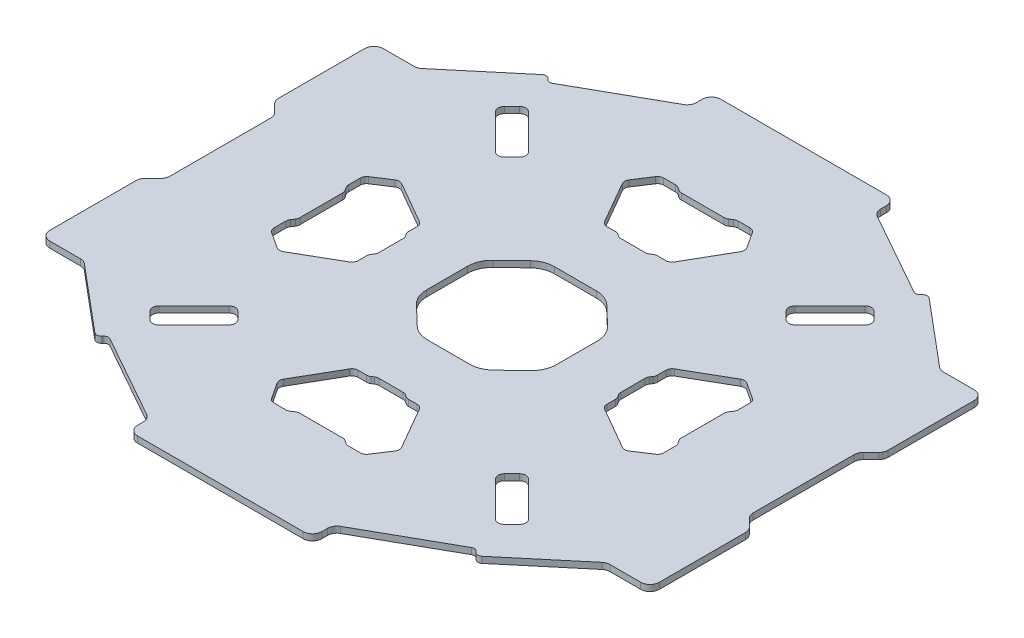
from build123d import *

# Parameters (mm, degrees)
ESTRUSIONE_ESTRUSIONE1_DEPTH = 2


with BuildPart() as part:
    # Schizzo3 → Estrusione-Estrusione1 (new body)
    with BuildSketch(Plane(origin=(0, 0, 0), x_dir=(1, 0, 0), z_dir=(0, 1, 0))):
        with BuildLine():
            Line((-226.062548699, 21.450885989), (-226.062548699, 53.965604615))
            ThreePointArc((-226.062548699, 53.965604615), (-226.290910101, 55.113654912), (-226.941228355, 56.086924959))
            Line((-226.941228355, 56.086924959), (-229.426509729, 58.572206333))
            ThreePointArc((-229.426509729, 58.572206333), (-230.076827983, 59.545476379), (-230.305189386, 60.693526677))
            Line((-230.305189386, 60.693526677), (-230.305189386, 88.450885989))
            ThreePointArc((-230.305189386, 88.450885989), (-229.426509729, 90.572206333), (-227.305189386, 91.450885989))
            Line((-227.305189386, 91.450885989), (-217.397100089, 91.450885989))
            ThreePointArc((-217.397100089, 91.450885989), (-216.371039659, 91.631808127), (-215.468737259, 92.15275266))
            Line((-215.468737259, 92.15275266), (-194.472922757, 109.770332866))
            ThreePointArc((-194.472922757, 109.770332866), (-193.378007728, 110.115558248), (-192.359674678, 109.585447615))
            Line((-192.359674678, 109.585447615), (-192.195095041, 109.389309242))
            ThreePointArc((-192.195095041, 109.389309242), (-191.315026723, 108.877807801), (-190.311081204, 109.045877314))
            Line((-190.311081204, 109.045877314), (-163.286363151, 124.235184019))
            ThreePointArc((-163.286363151, 124.235184019), (-162.166886622, 125.335432657), (-161.756257495, 126.850410704))
            Line((-161.756257495, 126.850410704), (-161.756257495, 128.708245302))
            ThreePointArc((-161.756257495, 128.708245302), (-160.877577839, 130.829565646), (-158.756257495, 131.708245302))
            Line((-158.756257495, 131.708245302), (-105.368839902, 131.708245302))
            ThreePointArc((-105.368839902, 131.708245302), (-103.247519558, 130.829565646), (-102.368839902, 128.708245302))
            Line((-102.368839902, 128.708245302), (-102.368839902, 126.850410704))
            ThreePointArc((-102.368839902, 126.850410704), (-101.958210775, 125.335432657), (-100.838734247, 124.235184019))
            Line((-100.838734247, 124.235184019), (-73.814016193, 109.045877314))
            ThreePointArc((-73.814016193, 109.045877314), (-72.810070674, 108.877807801), (-71.930002356, 109.389309242))
            Line((-71.930002356, 109.389309242), (-71.76542272, 109.585447615))
            ThreePointArc((-71.76542272, 109.585447615), (-70.747089669, 110.115558248), (-69.65217464, 109.770332865))
            Line((-69.65217464, 109.770332865), (-48.656360138, 92.15275266))
            ThreePointArc((-48.656360138, 92.15275266), (-47.754057739, 91.631808127), (-46.727997309, 91.450885989))
            Line((-46.727997309, 91.450885989), (-36.819908011, 91.450885989))
            ThreePointArc((-36.819908011, 91.450885989), (-34.698587668, 90.572206333), (-33.819908011, 88.450885989))
            Line((-33.819908011, 88.450885989), (-33.819908011, 60.693526677))
            ThreePointArc((-33.819908011, 60.693526677), (-34.048269414, 59.545476379), (-34.698587668, 58.572206333))
            Line((-34.698587668, 58.572206333), (-37.183869042, 56.086924959))
            ThreePointArc((-37.183869042, 56.086924959), (-37.834187296, 55.113654912), (-38.062548699, 53.965604615))
            Line((-38.062548699, 53.965604615), (-38.062548699, 21.450885989))
            ThreePointArc((-38.062548699, 21.450885989), (-37.834187296, 20.302835692), (-37.183869042, 19.329565646))
            Line((-37.183869042, 19.329565646), (-34.698587668, 16.844284272))
            ThreePointArc((-34.698587668, 16.844284272), (-34.048269414, 15.871014225), (-33.819908011, 14.722963928))
            Line((-33.819908011, 14.722963928), (-33.819908011, -13.034395385))
            ThreePointArc((-33.819908011, -13.034395385), (-34.698587668, -15.155715728), (-36.819908011, -16.034395385))
            Line((-36.819908011, -16.034395385), (-46.727997309, -16.034395385))
            ThreePointArc((-46.727997309, -16.034395385), (-47.754057739, -16.215317522), (-48.656360138, -16.736262055))
            Line((-48.656360138, -16.736262055), (-69.65217464, -34.353842261))
            ThreePointArc((-69.65217464, -34.353842261), (-70.747089669, -34.699067643), (-71.76542272, -34.168957011))
            Line((-71.76542272, -34.168957011), (-71.930002356, -33.972818637))
            ThreePointArc((-71.930002356, -33.972818637), (-72.810070674, -33.461317196), (-73.814016193, -33.629386709))
            Line((-73.814016193, -33.629386709), (-100.838734247, -48.818693414))
            ThreePointArc((-100.838734247, -48.818693414), (-101.958210775, -49.918942052), (-102.368839902, -51.433920099))
            Line((-102.368839902, -51.433920099), (-102.368839902, -53.291754698))
            ThreePointArc((-102.368839902, -53.291754698), (-103.247519558, -55.413075041), (-105.368839902, -56.291754698))
            Line((-105.368839902, -56.291754698), (-158.756257495, -56.291754698))
            ThreePointArc((-158.756257495, -56.291754698), (-160.877577839, -55.413075041), (-161.756257495, -53.291754698))
            Line((-161.756257495, -53.291754698), (-161.756257495, -51.433920099))
            ThreePointArc((-161.756257495, -51.433920099), (-162.166886622, -49.918942052), (-163.286363151, -48.818693414))
            Line((-163.286363151, -48.818693414), (-190.311081204, -33.629386709))
            ThreePointArc((-190.311081204, -33.629386709), (-191.315026723, -33.461317196), (-192.195095041, -33.972818637))
            Line((-192.195095041, -33.972818637), (-192.359674678, -34.168957011))
            ThreePointArc((-192.359674678, -34.168957011), (-193.378007728, -34.699067643), (-194.472922757, -34.353842261))
            Line((-194.472922757, -34.353842261), (-215.468737259, -16.736262055))
            ThreePointArc((-215.468737259, -16.736262055), (-216.371039659, -16.215317522), (-217.397100089, -16.034395385))
            Line((-217.397100089, -16.034395385), (-227.305189386, -16.034395385))
            ThreePointArc((-227.305189386, -16.034395385), (-229.426509729, -15.155715728), (-230.305189386, -13.034395385))
            Line((-230.305189386, -13.034395385), (-230.305189386, 14.722963928))
            ThreePointArc((-230.305189386, 14.722963928), (-230.076827983, 15.871014225), (-229.426509729, 16.844284272))
            Line((-229.426509729, 16.844284272), (-226.941228355, 19.329565646))
            ThreePointArc((-226.941228355, 19.329565646), (-226.290910101, 20.302835692), (-226.062548699, 21.450885989))
        make_face()
        with BuildLine():
            Line((-193.562548699, 30.804307286), (-193.562548699, 44.612183318))
            ThreePointArc((-193.562548699, 44.612183318), (-193.645860549, 45.183415789), (-193.888855234, 45.707057826))
            Line((-193.888855234, 45.707057826), (-194.544575535, 46.709432779))
            ThreePointArc((-194.544575535, 46.709432779), (-194.787570221, 47.233074816), (-194.870882071, 47.804307286))
            Line((-194.870882071, 47.804307286), (-194.870882071, 51.626654782))
            ThreePointArc((-194.870882071, 51.626654782), (-194.630107613, 52.578035617), (-193.965756578, 53.300348246))
            Line((-193.965756578, 53.300348246), (-188.785660294, 56.688994666))
            ThreePointArc((-188.785660294, 56.688994666), (-187.747791156, 57.014488633), (-186.693060988, 56.748663606))
            Line((-186.693060988, 56.748663606), (-173.159698407, 48.958849181))
            ThreePointArc((-173.159698407, 48.958849181), (-172.426029317, 48.226623731), (-172.157423206, 47.225486777))
            Line((-172.157423206, 47.225486777), (-172.157423206, 44.478000751))
            ThreePointArc((-172.157423206, 44.478000751), (-172.074111356, 43.90676828), (-171.83111667, 43.383126243))
            Line((-171.83111667, 43.383126243), (-171.388855234, 42.707057826))
            ThreePointArc((-171.388855234, 42.707057826), (-171.145860549, 42.183415789), (-171.062548699, 41.612183318))
            Line((-171.062548699, 41.612183318), (-171.062548699, 33.804307286))
            ThreePointArc((-171.062548699, 33.804307286), (-171.145860549, 33.233074816), (-171.388855234, 32.709432779))
            Line((-171.388855234, 32.709432779), (-171.83111667, 32.033364361))
            ThreePointArc((-171.83111667, 32.033364361), (-172.074111356, 31.509722324), (-172.157423206, 30.938489854))
            Line((-172.157423206, 30.938489854), (-172.157423206, 28.191003828))
            ThreePointArc((-172.157423206, 28.191003828), (-172.426029317, 27.189866874), (-173.159698407, 26.457641423))
            Line((-173.159698407, 26.457641423), (-186.693060988, 18.667826999))
            ThreePointArc((-186.693060988, 18.667826999), (-187.747791156, 18.402001971), (-188.785660294, 18.727495938))
            Line((-188.785660294, 18.727495938), (-193.965756578, 22.116142358))
            ThreePointArc((-193.965756578, 22.116142358), (-194.630107613, 22.838454988), (-194.870882071, 23.789835823))
            Line((-194.870882071, 23.789835823), (-194.870882071, 27.612183318))
            ThreePointArc((-194.870882071, 27.612183318), (-194.787570221, 28.183415789), (-194.544575535, 28.707057826))
            Line((-194.544575535, 28.707057826), (-193.888855234, 29.709432779))
            ThreePointArc((-193.888855234, 29.709432779), (-193.645860549, 30.233074816), (-193.562548699, 30.804307286))
        make_face(mode=Mode.SUBTRACT)
        with BuildLine():
            Line((-180.324443139, 80.666838895), (-191.638151638, 91.980547394))
            ThreePointArc((-191.638151638, 91.980547394), (-192.223938076, 93.394760956), (-191.638151638, 94.808974518))
            Line((-191.638151638, 94.808974518), (-189.163277904, 97.283848253))
            ThreePointArc((-189.163277904, 97.283848253), (-187.749064341, 97.86963469), (-186.334850779, 97.283848253))
            Line((-186.334850779, 97.283848253), (-175.02114228, 85.970139754))
            ThreePointArc((-175.02114228, 85.970139754), (-174.435355842, 84.555926191), (-175.02114228, 83.141712629))
            Line((-175.02114228, 83.141712629), (-177.496016014, 80.666838895))
            ThreePointArc((-177.496016014, 80.666838895), (-178.910229577, 80.081052457), (-180.324443139, 80.666838895))
        make_face(mode=Mode.SUBTRACT)
        with BuildLine():
            Line((-125.158610672, 99.208245313), (-138.966486704, 99.208245313))
            ThreePointArc((-138.966486704, 99.208245313), (-139.537719175, 99.291557163), (-140.061361211, 99.534551849))
            Line((-140.061361211, 99.534551849), (-141.063736164, 100.19027215))
            ThreePointArc((-141.063736164, 100.19027215), (-141.587378201, 100.433266835), (-142.158610672, 100.516578685))
            Line((-142.158610672, 100.516578685), (-145.980958167, 100.516578685))
            ThreePointArc((-145.980958167, 100.516578685), (-146.932339002, 100.275804227), (-147.654651632, 99.611453193))
            Line((-147.654651632, 99.611453193), (-151.043298052, 94.431356909))
            ThreePointArc((-151.043298052, 94.431356909), (-151.368792019, 93.39348777), (-151.102966992, 92.338757603))
            Line((-151.102966992, 92.338757603), (-143.313152567, 78.805395021))
            ThreePointArc((-143.313152567, 78.805395021), (-142.580927117, 78.071725931), (-141.579790163, 77.80311982))
            Line((-141.579790163, 77.80311982), (-138.832304136, 77.80311982))
            ThreePointArc((-138.832304136, 77.80311982), (-138.261071666, 77.71980797), (-137.737429629, 77.476813285))
            Line((-137.737429629, 77.476813285), (-137.061361211, 77.034551849))
            ThreePointArc((-137.061361211, 77.034551849), (-136.537719175, 76.791557163), (-135.966486704, 76.708245313))
            Line((-135.966486704, 76.708245313), (-128.158610672, 76.708245313))
            ThreePointArc((-128.158610672, 76.708245313), (-127.587378201, 76.791557163), (-127.063736164, 77.034551849))
            Line((-127.063736164, 77.034551849), (-126.387667747, 77.476813285))
            ThreePointArc((-126.387667747, 77.476813285), (-125.86402571, 77.71980797), (-125.292793239, 77.80311982))
            Line((-125.292793239, 77.80311982), (-122.545307213, 77.80311982))
            ThreePointArc((-122.545307213, 77.80311982), (-121.544170259, 78.071725931), (-120.811944809, 78.805395021))
            Line((-120.811944809, 78.805395021), (-113.022130384, 92.338757603))
            ThreePointArc((-113.022130384, 92.338757603), (-112.756305357, 93.39348777), (-113.081799324, 94.431356909))
            Line((-113.081799324, 94.431356909), (-116.470445744, 99.611453193))
            ThreePointArc((-116.470445744, 99.611453193), (-117.192758374, 100.275804227), (-118.144139208, 100.516578685))
            Line((-118.144139208, 100.516578685), (-121.966486704, 100.516578685))
            ThreePointArc((-121.966486704, 100.516578685), (-122.537719175, 100.433266835), (-123.061361211, 100.19027215))
            Line((-123.061361211, 100.19027215), (-124.063736164, 99.534551849))
            ThreePointArc((-124.063736164, 99.534551849), (-124.587378201, 99.291557163), (-125.158610672, 99.208245313))
        make_face(mode=Mode.SUBTRACT)
        with BuildLine():
            Line((-72.486945754, 94.808974513), (-74.961819488, 97.283848247))
            ThreePointArc((-74.961819488, 97.283848247), (-76.37603305, 97.869634685), (-77.790246613, 97.283848247))
            Line((-77.790246613, 97.283848247), (-89.103955112, 85.970139748))
            ThreePointArc((-89.103955112, 85.970139748), (-89.689741549, 84.555926186), (-89.103955112, 83.141712623))
            Line((-89.103955112, 83.141712623), (-86.629081378, 80.666838889))
            ThreePointArc((-86.629081378, 80.666838889), (-85.214867815, 80.081052452), (-83.800654253, 80.666838889))
            Line((-83.800654253, 80.666838889), (-72.486945754, 91.980547388))
            ThreePointArc((-72.486945754, 91.980547388), (-71.901159316, 93.394760951), (-72.486945754, 94.808974513))
        make_face(mode=Mode.SUBTRACT)
        with BuildLine():
            Line((-93.062548699, 41.612183318), (-93.062548699, 33.804307286))
            ThreePointArc((-93.062548699, 33.804307286), (-92.979236849, 33.233074816), (-92.736242163, 32.709432779))
            Line((-92.736242163, 32.709432779), (-92.293980727, 32.033364361))
            ThreePointArc((-92.293980727, 32.033364361), (-92.050986041, 31.509722324), (-91.967674191, 30.938489854))
            Line((-91.967674191, 30.938489854), (-91.967674191, 28.191003828))
            ThreePointArc((-91.967674191, 28.191003828), (-91.69906808, 27.189866874), (-90.96539899, 26.457641423))
            Line((-90.96539899, 26.457641423), (-77.432036409, 18.667826999))
            ThreePointArc((-77.432036409, 18.667826999), (-76.377306242, 18.402001971), (-75.339437103, 18.727495938))
            Line((-75.339437103, 18.727495938), (-70.159340819, 22.116142358))
            ThreePointArc((-70.159340819, 22.116142358), (-69.494989784, 22.838454988), (-69.254215326, 23.789835823))
            Line((-69.254215326, 23.789835823), (-69.254215326, 27.612183318))
            ThreePointArc((-69.254215326, 27.612183318), (-69.337527176, 28.183415789), (-69.580521862, 28.707057826))
            Line((-69.580521862, 28.707057826), (-70.236242163, 29.709432779))
            ThreePointArc((-70.236242163, 29.709432779), (-70.479236849, 30.233074816), (-70.562548699, 30.804307286))
            Line((-70.562548699, 30.804307286), (-70.562548699, 44.612183318))
            ThreePointArc((-70.562548699, 44.612183318), (-70.479236849, 45.183415789), (-70.236242163, 45.707057826))
            Line((-70.236242163, 45.707057826), (-69.580521862, 46.709432779))
            ThreePointArc((-69.580521862, 46.709432779), (-69.337527176, 47.233074816), (-69.254215326, 47.804307286))
            Line((-69.254215326, 47.804307286), (-69.254215326, 51.626654782))
            ThreePointArc((-69.254215326, 51.626654782), (-69.494989784, 52.578035617), (-70.159340819, 53.300348246))
            Line((-70.159340819, 53.300348246), (-75.339437103, 56.688994666))
            ThreePointArc((-75.339437103, 56.688994666), (-76.377306242, 57.014488633), (-77.432036409, 56.748663606))
            Line((-77.432036409, 56.748663606), (-90.96539899, 48.958849181))
            ThreePointArc((-90.96539899, 48.958849181), (-91.69906808, 48.226623731), (-91.967674191, 47.225486777))
            Line((-91.967674191, 47.225486777), (-91.967674191, 44.478000751))
            ThreePointArc((-91.967674191, 44.478000751), (-92.050986041, 43.90676828), (-92.293980727, 43.383126243))
            Line((-92.293980727, 43.383126243), (-92.736242163, 42.707057826))
            ThreePointArc((-92.736242163, 42.707057826), (-92.979236849, 42.183415789), (-93.062548699, 41.612183318))
        make_face(mode=Mode.SUBTRACT)
        with BuildLine():
            Line((-83.800654253, -5.250348285), (-72.486945754, -16.564056784))
            ThreePointArc((-72.486945754, -16.564056784), (-71.901159316, -17.978270346), (-72.486945754, -19.392483908))
            Line((-72.486945754, -19.392483908), (-74.961819488, -21.867357642))
            ThreePointArc((-74.961819488, -21.867357642), (-76.37603305, -22.45314408), (-77.790246613, -21.867357642))
            Line((-77.790246613, -21.867357642), (-89.103955112, -10.553649143))
            ThreePointArc((-89.103955112, -10.553649143), (-89.689741549, -9.139435581), (-89.103955112, -7.725222019))
            Line((-89.103955112, -7.725222019), (-86.629081378, -5.250348285))
            ThreePointArc((-86.629081378, -5.250348285), (-85.214867815, -4.664561847), (-83.800654253, -5.250348285))
        make_face(mode=Mode.SUBTRACT)
        with BuildLine():
            Line((-124.063736175, -24.118061233), (-123.061361222, -24.773781534))
            ThreePointArc((-123.061361222, -24.773781534), (-122.537719185, -25.01677622), (-121.966486715, -25.10008807))
            Line((-121.966486715, -25.10008807), (-118.144139219, -25.10008807))
            ThreePointArc((-118.144139219, -25.10008807), (-117.192758384, -24.859313612), (-116.470445755, -24.194962577))
            Line((-116.470445755, -24.194962577), (-113.081799335, -19.014866293))
            ThreePointArc((-113.081799335, -19.014866293), (-112.756305367, -17.976997155), (-113.022130395, -16.922266987))
            Line((-113.022130395, -16.922266987), (-120.811944819, -3.388904406))
            ThreePointArc((-120.811944819, -3.388904406), (-121.54417027, -2.655235316), (-122.545307224, -2.386629205))
            Line((-122.545307224, -2.386629205), (-125.29279325, -2.386629205))
            ThreePointArc((-125.29279325, -2.386629205), (-125.864025721, -2.303317355), (-126.387667757, -2.06032267))
            Line((-126.387667757, -2.06032267), (-127.063736175, -1.618061233))
            ThreePointArc((-127.063736175, -1.618061233), (-127.587378212, -1.375066548), (-128.158610682, -1.291754698))
            Line((-128.158610682, -1.291754698), (-135.966486715, -1.291754698))
            ThreePointArc((-135.966486715, -1.291754698), (-136.537719185, -1.375066548), (-137.061361222, -1.618061233))
            Line((-137.061361222, -1.618061233), (-137.73742964, -2.06032267))
            ThreePointArc((-137.73742964, -2.06032267), (-138.261071676, -2.303317355), (-138.832304147, -2.386629205))
            Line((-138.832304147, -2.386629205), (-141.579790173, -2.386629205))
            ThreePointArc((-141.579790173, -2.386629205), (-142.580927127, -2.655235316), (-143.313152578, -3.388904406))
            Line((-143.313152578, -3.388904406), (-151.102967002, -16.922266987))
            ThreePointArc((-151.102967002, -16.922266987), (-151.36879203, -17.976997155), (-151.043298062, -19.014866293))
            Line((-151.043298062, -19.014866293), (-147.654651643, -24.194962577))
            ThreePointArc((-147.654651643, -24.194962577), (-146.932339013, -24.859313612), (-145.980958178, -25.10008807))
            Line((-145.980958178, -25.10008807), (-142.158610682, -25.10008807))
            ThreePointArc((-142.158610682, -25.10008807), (-141.587378212, -25.01677622), (-141.063736175, -24.773781534))
            Line((-141.063736175, -24.773781534), (-140.061361222, -24.118061233))
            ThreePointArc((-140.061361222, -24.118061233), (-139.537719185, -23.875066548), (-138.966486715, -23.791754698))
            Line((-138.966486715, -23.791754698), (-125.158610682, -23.791754698))
            ThreePointArc((-125.158610682, -23.791754698), (-124.587378212, -23.875066548), (-124.063736175, -24.118061233))
        make_face(mode=Mode.SUBTRACT)
        with BuildLine():
            Line((-191.638151643, -19.392483908), (-189.163277909, -21.867357642))
            ThreePointArc((-189.163277909, -21.867357642), (-187.749064347, -22.45314408), (-186.334850784, -21.867357642))
            Line((-186.334850784, -21.867357642), (-175.021142286, -10.553649143))
            ThreePointArc((-175.021142286, -10.553649143), (-174.435355848, -9.139435581), (-175.021142286, -7.725222019))
            Line((-175.021142286, -7.725222019), (-177.49601602, -5.250348285))
            ThreePointArc((-177.49601602, -5.250348285), (-178.910229582, -4.664561847), (-180.324443144, -5.250348285))
            Line((-180.324443144, -5.250348285), (-191.638151643, -16.564056784))
            ThreePointArc((-191.638151643, -16.564056784), (-192.223938081, -17.978270346), (-191.638151643, -19.392483908))
        make_face(mode=Mode.SUBTRACT)
        with BuildLine():
            Line((-152.96705558, 31.121617228), (-152.96705558, 44.294873388))
            ThreePointArc((-152.96705558, 44.294873388), (-152.325268113, 47.434412894), (-150.502878502, 50.070223124))
            Line((-150.502878502, 50.070223124), (-144.383456263, 55.935848488))
            ThreePointArc((-144.383456263, 55.935848488), (-141.830685647, 57.583530406), (-138.847633342, 58.160498751))
            Line((-138.847633342, 58.160498751), (-125.277464045, 58.160498751))
            ThreePointArc((-125.277464045, 58.160498751), (-122.29441174, 57.583530406), (-119.741641123, 55.935848488))
            Line((-119.741641123, 55.935848488), (-113.622218885, 50.070223124))
            ThreePointArc((-113.622218885, 50.070223124), (-111.799829273, 47.434412894), (-111.158041807, 44.294873388))
            Line((-111.158041807, 44.294873388), (-111.158041807, 31.121617228))
            ThreePointArc((-111.158041807, 31.121617228), (-111.799829273, 27.982077721), (-113.622218885, 25.346267491))
            Line((-113.622218885, 25.346267491), (-119.741641123, 19.480642128))
            ThreePointArc((-119.741641123, 19.480642128), (-122.29441174, 17.83296021), (-125.277464045, 17.255991865))
            Line((-125.277464045, 17.255991865), (-138.847633342, 17.255991865))
            ThreePointArc((-138.847633342, 17.255991865), (-141.830685647, 17.83296021), (-144.383456263, 19.480642128))
            Line((-144.383456263, 19.480642128), (-150.502878502, 25.346267491))
            ThreePointArc((-150.502878502, 25.346267491), (-152.325268113, 27.982077721), (-152.96705558, 31.121617228))
        make_face(mode=Mode.SUBTRACT)
    extrude(amount=ESTRUSIONE_ESTRUSIONE1_DEPTH)


solid = part.part
